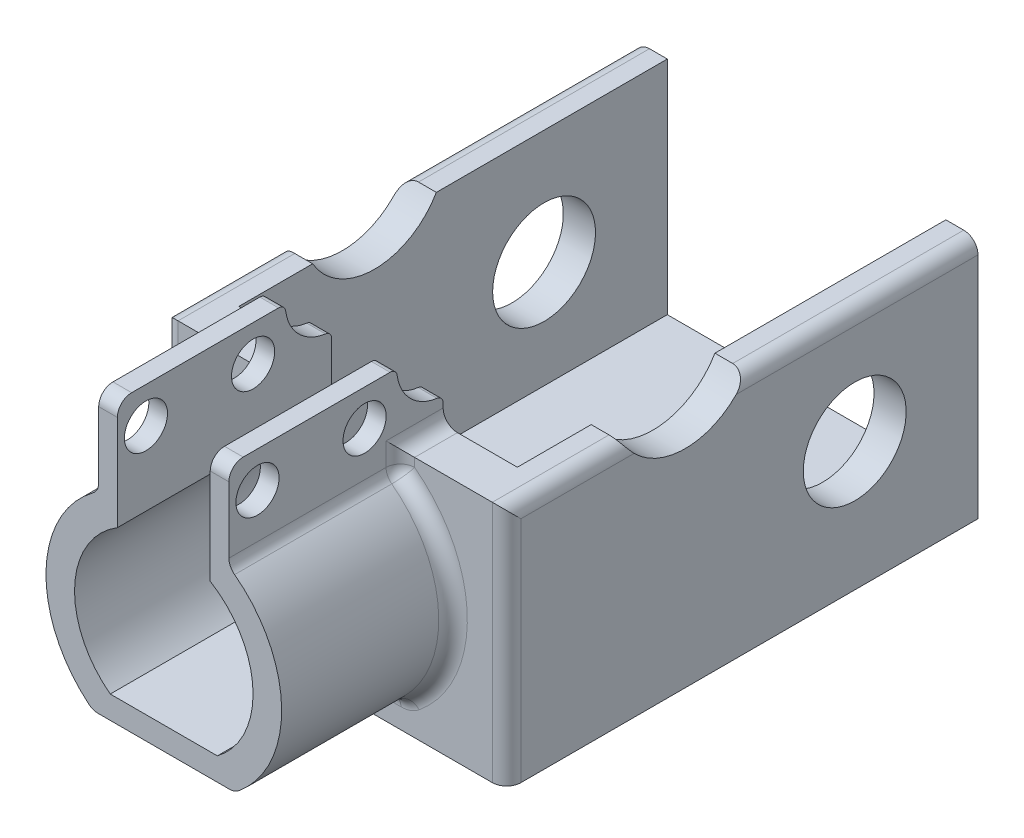
from build123d import *

# Parameters (mm, degrees)
BOSS_EXTRUDE1_DEPTH      = 6.100789
BOSS_EXTRUDE1_DEPTH_BACK = 8.899211
SKETCH2_R                = 1.51
CUT_EXTRUDE1_DEPTH       = 13.807078357
FILLET1_R                = 1
SKETCH3_W                = 24
SKETCH3_H                = 17
BOSS_EXTRUDE2_DEPTH      = 30
BOSS_EXTRUDE2_DEPTH_BACK = 3
SKETCH4_W                = 19.5
SKETCH4_H                = 15.5
CUT_EXTRUDE2_DEPTH       = 30
CUT_EXTRUDE6_DEPTH       = 3
FILLET2_R                = 1
SKETCH7_R                = 3.6
CUT_EXTRUDE7_DEPTH       = 25
CUT_EXTRUDE8_DEPTH       = 1
CUT_EXTRUDE8_DEPTH_BACK  = 25
CUT_EXTRUDE9_DEPTH       = 17.558078457
FILLET3_R                = 0.5


with BuildPart() as part:
    # Sketch1 → Boss-Extrude1 (new body, two sides)
    with BuildSketch(Plane.XY) as boss_extrude1_sk:
        with BuildLine():
            Line((4.558078357, 79.172152098), (3.25, 79.172152098))
            Line((3.25, 79.172152098), (3.25, 71.489520457))
            ThreePointArc((3.25, 71.489520457), (6.241751571, 66.453047962), (3.748333096, 61.152152098))
            Line((3.748333096, 61.152152098), (-3.748333096, 61.152152098))
            ThreePointArc((-3.748333096, 61.152152098), (-6.241751571, 66.453047962), (-3.25, 71.489520457))
            Line((-3.25, 71.489520457), (-3.25, 79.172152098))
            Line((-3.25, 79.172152098), (-4.558078357, 79.172152098))
            Line((-4.558078357, 79.172152098), (-4.558078357, 73.02746465))
            ThreePointArc((-4.558078357, 73.02746465), (-8.245549035, 66.39073565), (-4.947991632, 59.551896057))
            Line((-4.947991632, 59.551896057), (4.947991632, 59.551896057))
            ThreePointArc((4.947991632, 59.551896057), (8.245549035, 66.39073565), (4.558078357, 73.02746465))
            Line((4.558078357, 73.02746465), (4.558078357, 79.172152098))
        make_face()
    extrude(amount=BOSS_EXTRUDE1_DEPTH)
    extrude(boss_extrude1_sk.sketch, amount=-BOSS_EXTRUDE1_DEPTH_BACK)

    # Sketch2 → Cut-Extrude1 (cut, through all)
    with BuildSketch(Plane.ZY.offset(4.558078357)):
        with Locations((4.10078902, 76.662152098)):
            Circle(SKETCH2_R)
        with Locations((-3.39921098, 76.662152098)):
            Circle(SKETCH2_R)
    extrude(amount=-CUT_EXTRUDE1_DEPTH, mode=Mode.SUBTRACT)

    # Fillet1
    fillet1_edges = [part.edges().sort_by_distance(p)[0] for p in [
        (4.558078357, 73.02746465, -1.399211),
        (4.947991632, 59.551896057, -1.399211),
        (-4.947991632, 59.551896057, -1.399211),
        (-4.558078357, 73.02746465, -1.399211),
        (-3.904039179, 79.172152098, 6.100789),
        (3.904039179, 79.172152098, 6.100789),
        (3.904039179, 79.172152098, -8.899211),
        (-3.904039179, 79.172152098, -8.899211),
    ]]
    fillet(fillet1_edges, radius=FILLET1_R)

    # Sketch3 → Boss-Extrude2 (add, two sides)
    with BuildSketch(Plane(origin=(0, 0, -8.89921098), x_dir=(-1, 0, 0), z_dir=(0, 0, -1))) as boss_extrude2_sk:
        with Locations((0, 65.652152098)):
            Rectangle(SKETCH3_W, SKETCH3_H)
    extrude(amount=BOSS_EXTRUDE2_DEPTH)
    extrude(boss_extrude2_sk.sketch, amount=-BOSS_EXTRUDE2_DEPTH_BACK)

    # Sketch4 → Cut-Extrude2 (cut)
    with BuildSketch(Plane(origin=(0, 0, -38.89921098), x_dir=(-1, 0, 0), z_dir=(0, 0, -1))):
        with Locations((0, 66.402152098)):
            Rectangle(SKETCH4_W, SKETCH4_H)
    extrude(amount=-CUT_EXTRUDE2_DEPTH, mode=Mode.SUBTRACT)

    # Sketch6 → Cut-Extrude6 (cut)
    with BuildSketch(Plane(origin=(0, 0, -8.89921098), x_dir=(-1, 0, 0), z_dir=(0, 0, -1))):
        with BuildLine():
            Line((-3.25, 74.152152098), (-3.25, 71.489520457))
            ThreePointArc((-3.25, 71.489520457), (-6.241751571, 66.453047962), (-3.748333096, 61.152152098))
            Line((-3.748333096, 61.152152098), (3.748333096, 61.152152098))
            ThreePointArc((3.748333096, 61.152152098), (6.241751571, 66.453047962), (3.25, 71.489520457))
            Line((3.25, 71.489520457), (3.25, 74.152152098))
            Line((3.25, 74.152152098), (-3.25, 74.152152098))
        make_face()
    extrude(amount=-CUT_EXTRUDE6_DEPTH, mode=Mode.SUBTRACT)

    # Fillet2
    fillet2_edges = [part.edges().sort_by_distance(p)[0] for p in [
        (-4.663388941, 73.09814661, -5.89921098),
        (12, 74.152152098, -22.39921098),
        (-4.558078357, 74.152152098, -7.39921099),
        (4.558078357, 73.848493734, -5.89921098),
        (4.663388941, 73.09814661, -5.89921098),
        (8.247069912, 66.330586564, -5.89921098),
        (0, 59.551896057, -5.89921098),
        (-8.247069912, 66.330586564, -5.89921098),
        (-4.558078357, 73.848493734, -5.89921098),
        (12, 65.652152098, -5.89921098),
        (4.558078357, 74.152152098, -7.39921099),
        (-12, 74.152152098, -22.39921098),
        (-12, 65.652152098, -5.89921098),
        (-4.939958239, 59.610472754, -5.89921098),
        (4.939958239, 59.610472754, -5.89921098),
    ]]
    fillet(fillet2_edges, radius=FILLET2_R)

    # Sketch7 → Cut-Extrude7 (cut, through all)
    with BuildSketch(Plane.ZY.offset(12)):
        with Locations((-30.270250022, 66.152152098)):
            Circle(SKETCH7_R)
    extrude(amount=-CUT_EXTRUDE7_DEPTH, mode=Mode.SUBTRACT)

    # Sketch8 → Cut-Extrude8 (cut, two sides)
    with BuildSketch(Plane(origin=(12, 0, 0), x_dir=(0, 0, -1), z_dir=(1, 0, 0))) as cut_extrude8_sk:
        with BuildLine():
            Line((14.069083961, 74.152152098), (22.729337999, 74.152152098))
            ThreePointArc((22.729337999, 74.152152098), (18.39921098, 71.652152098), (14.069083961, 74.152152098))
        make_face()
    extrude(amount=CUT_EXTRUDE8_DEPTH, mode=Mode.SUBTRACT)
    extrude(cut_extrude8_sk.sketch, amount=-CUT_EXTRUDE8_DEPTH_BACK, mode=Mode.SUBTRACT)

    # Sketch9 → Cut-Extrude9 (cut, through all)
    with BuildSketch(Plane.ZY.offset(4.558078357)):
        with BuildLine():
            Line((-8.89921098, 78.172152098), (-8.89921098, 75.922152098))
            ThreePointArc((-8.89921098, 75.922152098), (-6.601113941, 76.874055059), (-5.64921098, 79.172152098))
            Line((-5.64921098, 79.172152098), (-7.89921098, 79.172152098))
            ThreePointArc((-7.89921098, 79.172152098), (-8.606317761, 78.879258879), (-8.89921098, 78.172152098))
        make_face()
    extrude(amount=-CUT_EXTRUDE9_DEPTH, mode=Mode.SUBTRACT)

    # Fillet3
    fillet3_edges = [part.edges().sort_by_distance(p)[0] for p in [
        (-3.904039179, 79.172152098, -5.64921098),
        (3.904039179, 79.172152098, -5.64921098),
        (-3.904039179, 75.922152098, -8.89921098),
        (3.904039179, 75.922152098, -8.89921098),
    ]]
    fillet(fillet3_edges, radius=FILLET3_R)


solid = part.part
